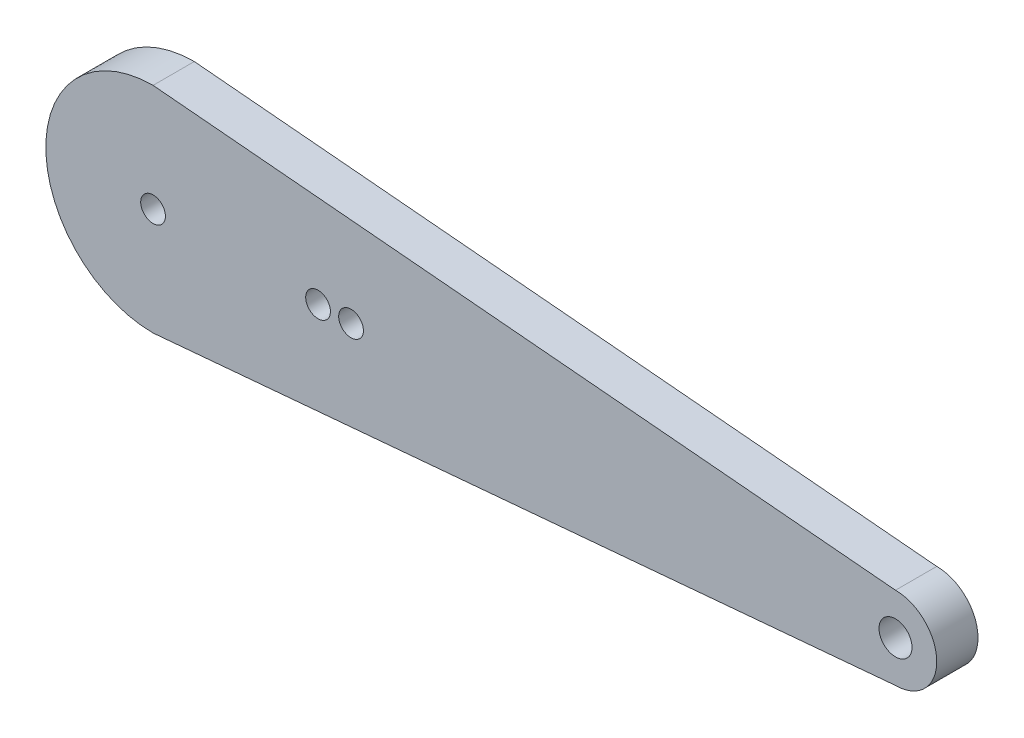
from build123d import *

# Parameters (mm, degrees)
SKETCH_1_R      = 1.5
SKETCH_1_R_2    = 2
EXTRUDE_1_DEPTH = 5


with BuildPart() as part:
    # 草图1 → 凸台-拉伸1 (new body)
    with BuildSketch(Plane.XY):
        with BuildLine():
            Line((-45, 13), (45, 5))
            ThreePointArc((45, 5), (50, 0), (45, -5))
            Line((45, -5), (-45, -13))
            ThreePointArc((-45, -13), (-58, 0), (-45, 13))
        make_face()
        with Locations((-45, 0)):
            Circle(SKETCH_1_R, mode=Mode.SUBTRACT)
        with Locations((45, 0)):
            Circle(SKETCH_1_R_2, mode=Mode.SUBTRACT)
        with Locations((-25, 0)):
            Circle(SKETCH_1_R, mode=Mode.SUBTRACT)
        with Locations((-21, 0)):
            Circle(SKETCH_1_R, mode=Mode.SUBTRACT)
    extrude(amount=EXTRUDE_1_DEPTH)


solid = part.part
